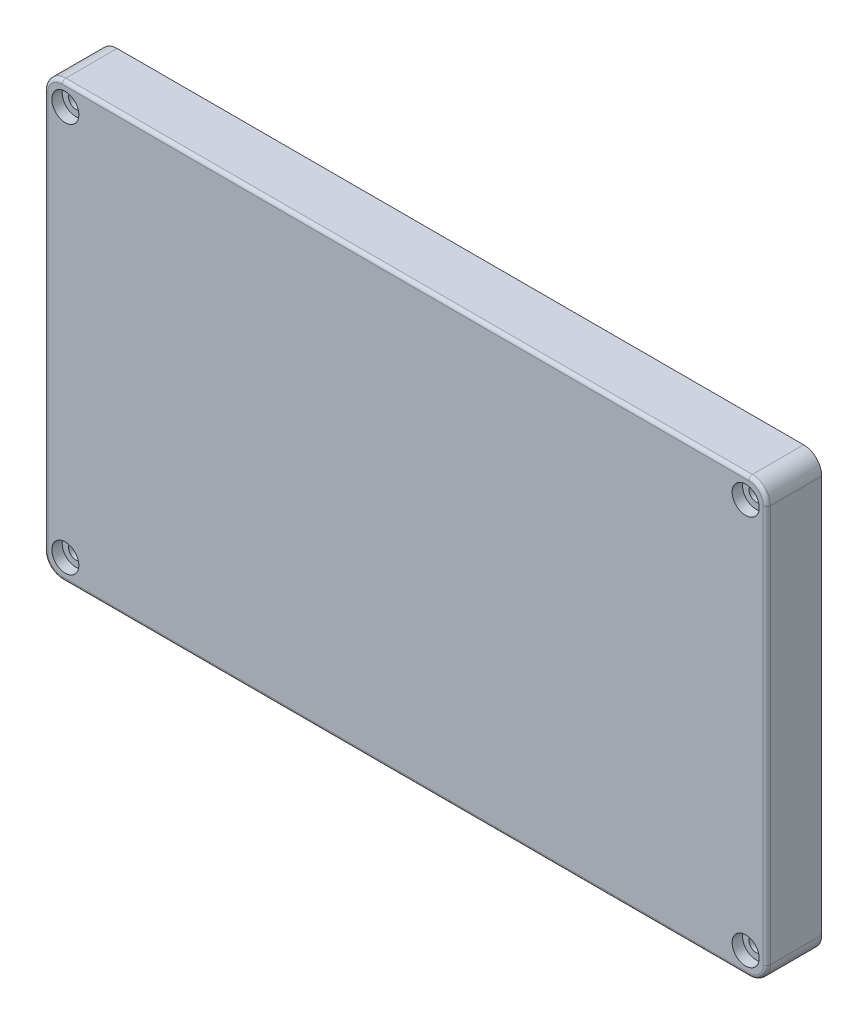
from build123d import *

# Parameters (mm, degrees)
SKETCH1_R           = 2
BOSS_EXTRUDE1_DEPTH = 15.2
SKETCH2_R           = 3.75
CUT_EXTRUDE1_DEPTH  = 2.9
FILLET1_R           = 1
CUT_EXTRUDE2_DEPTH  = 11.2
BOSS_EXTRUDE2_DEPTH = 1
CUT_EXTRUDE3_DEPTH  = 2.5
CUT_EXTRUDE4_DEPTH  = 11.2


with BuildPart() as part:
    # Sketch1 → Boss-Extrude1 (new body)
    with BuildSketch(Plane.XY):
        with BuildLine():
            Line((-95, -60), (95, -60))
            ThreePointArc((95, -60), (98.535533906, -58.535533906), (100, -55))
            Line((100, -55), (100, 55))
            ThreePointArc((100, 55), (98.535533906, 58.535533906), (95, 60))
            Line((95, 60), (-95, 60))
            ThreePointArc((-95, 60), (-98.535533906, 58.535533906), (-100, 55))
            Line((-100, 55), (-100, -55))
            ThreePointArc((-100, -55), (-98.535533906, -58.535533906), (-95, -60))
        make_face()
        with Locations((94.15, -54)):
            Circle(SKETCH1_R, mode=Mode.SUBTRACT)
        with Locations((94.15, 54)):
            Circle(SKETCH1_R, mode=Mode.SUBTRACT)
        with Locations((-94.15, 54)):
            Circle(SKETCH1_R, mode=Mode.SUBTRACT)
        with Locations((-94.15, -54)):
            Circle(SKETCH1_R, mode=Mode.SUBTRACT)
    extrude(amount=BOSS_EXTRUDE1_DEPTH)

    # Sketch2 → Cut-Extrude1 (cut)
    with BuildSketch(Plane.XY.offset(15.2)):
        with Locations((-94.15, 54)):
            Circle(SKETCH2_R)
        with Locations((94.15, 54)):
            Circle(SKETCH2_R)
        with Locations((94.15, -54)):
            Circle(SKETCH2_R)
        with Locations((-94.15, -54)):
            Circle(SKETCH2_R)
    extrude(amount=-CUT_EXTRUDE1_DEPTH, mode=Mode.SUBTRACT)

    # Fillet1
    fillet1_edges = [part.edges().sort_by_distance(p)[0] for p in [
        (98.535533906, -58.535533906, 15.2),
        (100, 0, 15.2),
        (98.535533906, 58.535533906, 15.2),
        (0, 60, 15.2),
        (-98.535533906, 58.535533906, 15.2),
        (-100, 0, 15.2),
        (-98.535533906, -58.535533906, 15.2),
        (0, -60, 15.2),
    ]]
    fillet(fillet1_edges, radius=FILLET1_R)

    # Sketch3 → Cut-Extrude2 (cut)
    with BuildSketch(Plane(origin=(0, 0, 0), x_dir=(-1, 0, 0), z_dir=(0, 0, -1))):
        with BuildLine():
            Line((86.35, -52.7), (86.35, -42.7))
            ThreePointArc((86.35, -42.7), (87.960912703, -38.810912703), (91.85, -37.2))
            Line((91.85, -37.2), (92.7, -37.2))
            ThreePointArc((92.7, -37.2), (94.467766953, -36.467766953), (95.2, -34.7))
            Line((95.2, -34.7), (95.2, 34.7))
            ThreePointArc((95.2, 34.7), (94.467766953, 36.467766953), (92.7, 37.2))
            Line((92.7, 37.2), (91.85, 37.2))
            ThreePointArc((91.85, 37.2), (87.960912703, 38.810912703), (86.35, 42.7))
            Line((86.35, 42.7), (86.35, 52.7))
            ThreePointArc((86.35, 52.7), (85.617766953, 54.467766953), (83.85, 55.2))
            Line((83.85, 55.2), (-83.85, 55.2))
            ThreePointArc((-83.85, 55.2), (-85.617766953, 54.467766953), (-86.35, 52.7))
            Line((-86.35, 52.7), (-86.35, 42.7))
            ThreePointArc((-86.35, 42.7), (-87.960912703, 38.810912703), (-91.85, 37.2))
            Line((-91.85, 37.2), (-92.7, 37.2))
            ThreePointArc((-92.7, 37.2), (-94.467766953, 36.467766953), (-95.2, 34.7))
            Line((-95.2, 34.7), (-95.2, -34.7))
            ThreePointArc((-95.2, -34.7), (-94.467766953, -36.467766953), (-92.7, -37.2))
            Line((-92.7, -37.2), (-91.85, -37.2))
            ThreePointArc((-91.85, -37.2), (-87.960912703, -38.810912703), (-86.35, -42.7))
            Line((-86.35, -42.7), (-86.35, -52.7))
            ThreePointArc((-86.35, -52.7), (-85.617766953, -54.467766953), (-83.85, -55.2))
            Line((-83.85, -55.2), (83.85, -55.2))
            ThreePointArc((83.85, -55.2), (85.617766953, -54.467766953), (86.35, -52.7))
        make_face()
    extrude(amount=-CUT_EXTRUDE2_DEPTH, mode=Mode.SUBTRACT)

    # Sketch4 → Boss-Extrude2 (add)
    with BuildSketch(Plane(origin=(0, 0, 0), x_dir=(-1, 0, 0), z_dir=(0, 0, -1))):
        with BuildLine():
            Line((-83.85, -56.2), (83.85, -56.2))
            ThreePointArc((83.85, -56.2), (86.324873734, -55.174873734), (87.35, -52.7))
            Line((87.35, -52.7), (87.35, -42.7))
            ThreePointArc((87.35, -42.7), (88.668019485, -39.518019485), (91.85, -38.2))
            Line((91.85, -38.2), (92.7, -38.2))
            ThreePointArc((92.7, -38.2), (95.174873734, -37.174873734), (96.2, -34.7))
            Line((96.2, -34.7), (96.2, 34.7))
            ThreePointArc((96.2, 34.7), (95.174873734, 37.174873734), (92.7, 38.2))
            Line((92.7, 38.2), (91.85, 38.2))
            ThreePointArc((91.85, 38.2), (88.668019485, 39.518019485), (87.35, 42.7))
            Line((87.35, 42.7), (87.35, 52.7))
            ThreePointArc((87.35, 52.7), (86.324873734, 55.174873734), (83.85, 56.2))
            Line((83.85, 56.2), (-83.85, 56.2))
            ThreePointArc((-83.85, 56.2), (-86.324873734, 55.174873734), (-87.35, 52.7))
            Line((-87.35, 52.7), (-87.35, 42.7))
            ThreePointArc((-87.35, 42.7), (-88.668019485, 39.518019485), (-91.85, 38.2))
            Line((-91.85, 38.2), (-92.7, 38.2))
            ThreePointArc((-92.7, 38.2), (-95.174873734, 37.174873734), (-96.2, 34.7))
            Line((-96.2, 34.7), (-96.2, -34.7))
            ThreePointArc((-96.2, -34.7), (-95.174873734, -37.174873734), (-92.7, -38.2))
            Line((-92.7, -38.2), (-91.85, -38.2))
            ThreePointArc((-91.85, -38.2), (-88.668019485, -39.518019485), (-87.35, -42.7))
            Line((-87.35, -42.7), (-87.35, -52.7))
            ThreePointArc((-87.35, -52.7), (-86.324873734, -55.174873734), (-83.85, -56.2))
        make_face()
        with BuildLine():
            Line((86.35, -52.7), (86.35, -42.7))
            ThreePointArc((86.35, -42.7), (87.960912703, -38.810912703), (91.85, -37.2))
            Line((91.85, -37.2), (92.7, -37.2))
            ThreePointArc((92.7, -37.2), (94.467766953, -36.467766953), (95.2, -34.7))
            Line((95.2, -34.7), (95.2, 34.7))
            ThreePointArc((95.2, 34.7), (94.467766953, 36.467766953), (92.7, 37.2))
            Line((92.7, 37.2), (91.85, 37.2))
            ThreePointArc((91.85, 37.2), (87.960912703, 38.810912703), (86.35, 42.7))
            Line((86.35, 42.7), (86.35, 52.7))
            ThreePointArc((86.35, 52.7), (85.617766953, 54.467766953), (83.85, 55.2))
            Line((83.85, 55.2), (-83.85, 55.2))
            ThreePointArc((-83.85, 55.2), (-85.617766953, 54.467766953), (-86.35, 52.7))
            Line((-86.35, 52.7), (-86.35, 42.7))
            ThreePointArc((-86.35, 42.7), (-87.960912703, 38.810912703), (-91.85, 37.2))
            Line((-91.85, 37.2), (-92.7, 37.2))
            ThreePointArc((-92.7, 37.2), (-94.467766953, 36.467766953), (-95.2, 34.7))
            Line((-95.2, 34.7), (-95.2, -34.7))
            ThreePointArc((-95.2, -34.7), (-94.467766953, -36.467766953), (-92.7, -37.2))
            Line((-92.7, -37.2), (-91.85, -37.2))
            ThreePointArc((-91.85, -37.2), (-87.960912703, -38.810912703), (-86.35, -42.7))
            Line((-86.35, -42.7), (-86.35, -52.7))
            ThreePointArc((-86.35, -52.7), (-85.617766953, -54.467766953), (-83.85, -55.2))
            Line((-83.85, -55.2), (83.85, -55.2))
            ThreePointArc((83.85, -55.2), (85.617766953, -54.467766953), (86.35, -52.7))
        make_face(mode=Mode.SUBTRACT)
    extrude(amount=BOSS_EXTRUDE2_DEPTH)

    # Sketch5 → Cut-Extrude3 (cut)
    with BuildSketch(Plane(origin=(0, 0, 0), x_dir=(-1, 0, 0), z_dir=(0, 0, -1))):
        with BuildLine():
            Line((92.7, 40.2), (91.85, 40.2))
            ThreePointArc((91.85, 40.2), (90.082233047, 40.932233047), (89.35, 42.7))
            Line((89.35, 42.7), (89.35, 52.7))
            ThreePointArc((89.35, 52.7), (87.739087297, 56.589087297), (83.85, 58.2))
            Line((83.85, 58.2), (-83.85, 58.2))
            ThreePointArc((-83.85, 58.2), (-87.739087297, 56.589087297), (-89.35, 52.7))
            Line((-89.35, 52.7), (-89.35, 42.7))
            ThreePointArc((-89.35, 42.7), (-90.082233047, 40.932233047), (-91.85, 40.2))
            Line((-91.85, 40.2), (-92.7, 40.2))
            ThreePointArc((-92.7, 40.2), (-96.589087297, 38.589087297), (-98.2, 34.7))
            Line((-98.2, 34.7), (-98.2, -34.7))
            ThreePointArc((-98.2, -34.7), (-96.589087297, -38.589087297), (-92.7, -40.2))
            Line((-92.7, -40.2), (-91.85, -40.2))
            ThreePointArc((-91.85, -40.2), (-90.082233047, -40.932233047), (-89.35, -42.7))
            Line((-89.35, -42.7), (-89.35, -52.7))
            ThreePointArc((-89.35, -52.7), (-87.739087297, -56.589087297), (-83.85, -58.2))
            Line((-83.85, -58.2), (83.85, -58.2))
            ThreePointArc((83.85, -58.2), (87.739087297, -56.589087297), (89.35, -52.7))
            Line((89.35, -52.7), (89.35, -42.7))
            ThreePointArc((89.35, -42.7), (90.082233047, -40.932233047), (91.85, -40.2))
            Line((91.85, -40.2), (92.7, -40.2))
            ThreePointArc((92.7, -40.2), (96.589087297, -38.589087297), (98.2, -34.7))
            Line((98.2, -34.7), (98.2, 34.7))
            ThreePointArc((98.2, 34.7), (96.589087297, 38.589087297), (92.7, 40.2))
        make_face()
        with BuildLine():
            Line((87.35, 42.7), (87.35, 52.7))
            ThreePointArc((87.35, 52.7), (86.324873734, 55.174873734), (83.85, 56.2))
            Line((83.85, 56.2), (-83.85, 56.2))
            ThreePointArc((-83.85, 56.2), (-86.324873734, 55.174873734), (-87.35, 52.7))
            Line((-87.35, 52.7), (-87.35, 42.7))
            ThreePointArc((-87.35, 42.7), (-88.668019485, 39.518019485), (-91.85, 38.2))
            Line((-91.85, 38.2), (-92.7, 38.2))
            ThreePointArc((-92.7, 38.2), (-95.174873734, 37.174873734), (-96.2, 34.7))
            Line((-96.2, 34.7), (-96.2, -34.7))
            ThreePointArc((-96.2, -34.7), (-95.174873734, -37.174873734), (-92.7, -38.2))
            Line((-92.7, -38.2), (-91.85, -38.2))
            ThreePointArc((-91.85, -38.2), (-88.668019485, -39.518019485), (-87.35, -42.7))
            Line((-87.35, -42.7), (-87.35, -52.7))
            ThreePointArc((-87.35, -52.7), (-86.324873734, -55.174873734), (-83.85, -56.2))
            Line((-83.85, -56.2), (83.85, -56.2))
            ThreePointArc((83.85, -56.2), (86.324873734, -55.174873734), (87.35, -52.7))
            Line((87.35, -52.7), (87.35, -42.7))
            ThreePointArc((87.35, -42.7), (88.668019485, -39.518019485), (91.85, -38.2))
            Line((91.85, -38.2), (92.7, -38.2))
            ThreePointArc((92.7, -38.2), (95.174873734, -37.174873734), (96.2, -34.7))
            Line((96.2, -34.7), (96.2, 34.7))
            ThreePointArc((96.2, 34.7), (95.174873734, 37.174873734), (92.7, 38.2))
            Line((92.7, 38.2), (91.85, 38.2))
            ThreePointArc((91.85, 38.2), (88.668019485, 39.518019485), (87.35, 42.7))
        make_face(mode=Mode.SUBTRACT)
    extrude(amount=-CUT_EXTRUDE3_DEPTH, mode=Mode.SUBTRACT)

    # Sketch6 → Cut-Extrude4 (cut)
    with BuildSketch(Plane(origin=(0, 0, 0), x_dir=(-1, 0, 0), z_dir=(0, 0, -1))):
        with BuildLine():
            Line((-97.6, 49.275595276), (-97.6, 39.838093031))
            ThreePointArc((-97.6, 39.838093031), (-95.339085019, 41.291299588), (-92.7, 41.8))
            Line((-92.7, 41.8), (-91.85, 41.8))
            ThreePointArc((-91.85, 41.8), (-91.213603897, 42.063603897), (-90.95, 42.7))
            Line((-90.95, 42.7), (-90.95, 49.102806926))
            ThreePointArc((-90.95, 49.102806926), (-94.301950497, 48.151973748), (-97.6, 49.275595276))
        make_face()
        with BuildLine():
            Line((-97.6, -39.838093031), (-97.6, -49.275595276))
            ThreePointArc((-97.6, -49.275595276), (-94.301950497, -48.151973748), (-90.95, -49.102806926))
            Line((-90.95, -49.102806926), (-90.95, -42.7))
            ThreePointArc((-90.95, -42.7), (-91.213603897, -42.063603897), (-91.85, -41.8))
            Line((-91.85, -41.8), (-92.7, -41.8))
            ThreePointArc((-92.7, -41.8), (-95.339085019, -41.291299588), (-97.6, -39.838093031))
        make_face()
        with BuildLine():
            Line((90.95, -42.7), (90.95, -49.102806926))
            ThreePointArc((90.95, -49.102806926), (94.301950497, -48.151973748), (97.6, -49.275595276))
            Line((97.6, -49.275595276), (97.6, -39.838093031))
            ThreePointArc((97.6, -39.838093031), (95.339085019, -41.291299588), (92.7, -41.8))
            Line((92.7, -41.8), (91.85, -41.8))
            ThreePointArc((91.85, -41.8), (91.213603897, -42.063603897), (90.95, -42.7))
        make_face()
        with BuildLine():
            ThreePointArc((92.7, 41.8), (95.339085019, 41.291299588), (97.6, 39.838093031))
            Line((97.6, 39.838093031), (97.6, 49.275595276))
            ThreePointArc((97.6, 49.275595276), (94.301950497, 48.151973748), (90.95, 49.102806926))
            Line((90.95, 49.102806926), (90.95, 42.7))
            ThreePointArc((90.95, 42.7), (91.213603897, 42.063603897), (91.85, 41.8))
            Line((91.85, 41.8), (92.7, 41.8))
        make_face()
    extrude(amount=-CUT_EXTRUDE4_DEPTH, mode=Mode.SUBTRACT)


solid = part.part
